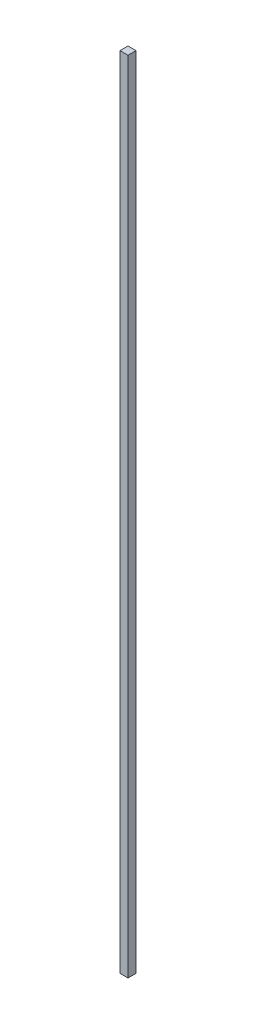
from build123d import *

# Parameters (mm, degrees)
SKETCH1_W           = 20
SKETCH1_H           = 20
BOSS_EXTRUDE1_DEPTH = 2000


with BuildPart() as part:
    # Sketch1 → Boss-Extrude1 (new body)
    with BuildSketch(Plane(origin=(0, 0, 0), x_dir=(1, 0, 0), z_dir=(0, 1, 0))):
        with Locations((10, -10)):
            Rectangle(SKETCH1_W, SKETCH1_H)
    extrude(amount=BOSS_EXTRUDE1_DEPTH)


solid = part.part
